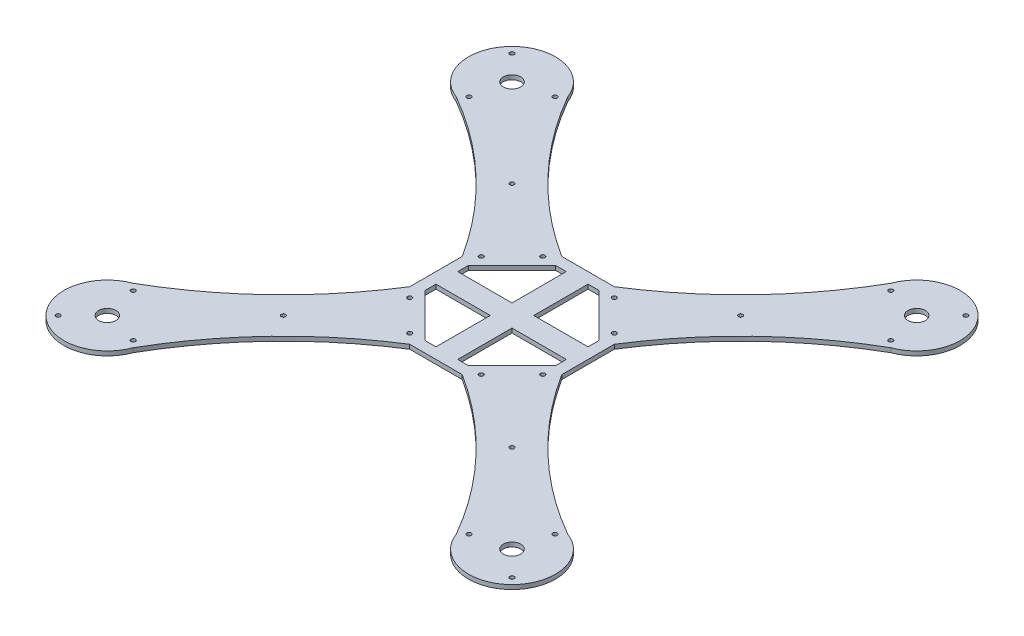
from build123d import *

# Parameters (mm, degrees)
SKETCH2_R           = 4
SKETCH2_R_2         = 1
BOSS_EXTRUDE1_DEPTH = 2
CIRPATTERN1_COUNT   = 4


with BuildPart() as part:
    # Sketch2 → Boss-Extrude1 (new body)
    with BuildSketch(Plane(origin=(0, 0, 0), x_dir=(1, 0, 0), z_dir=(0, 1, 0))):
        with BuildLine():
            Line((0, 0), (35, 0))
            Line((35, 0), (35, 12.071067812))
            ThreePointArc((35, 12.071067812), (63.703714022, 47.158503121), (99.989485852, 74.331542663))
            ThreePointArc((99.989485852, 74.331542663), (107.253909229, 107.253909229), (74.331542663, 99.989485852))
            ThreePointArc((74.331542663, 99.989485852), (47.158503121, 63.703714022), (12.071067812, 35))
            Line((12.071067812, 35), (0, 35))
            Line((0, 35), (0, 0))
        make_face()
        with Locations((93.111773605, 93.111773605)):
            Circle(SKETCH2_R, mode=Mode.SUBTRACT)
        with Locations((52.588388778, 52.588388778)):
            Circle(SKETCH2_R_2, mode=Mode.SUBTRACT)
        with Locations((16.464466094, 30.606601718)):
            Circle(SKETCH2_R_2, mode=Mode.SUBTRACT)
        with Locations((30.606601718, 16.464466094)):
            Circle(SKETCH2_R_2, mode=Mode.SUBTRACT)
        with Locations((97.060009194, 77.261019321)):
            Circle(SKETCH2_R_2, mode=Mode.SUBTRACT)
        with Locations((77.261019321, 97.060009194)):
            Circle(SKETCH2_R_2, mode=Mode.SUBTRACT)
        with Locations((104.425482104, 104.425482104)):
            Circle(SKETCH2_R_2, mode=Mode.SUBTRACT)
        Polygon((5, 30), (5, 5), (30, 5), (30, 10), (10, 30), align=None, mode=Mode.SUBTRACT)
    boss_extrude1 = extrude(amount=BOSS_EXTRUDE1_DEPTH)

    # CirPattern1: Boss-Extrude1 ×4 about axis
    cirpattern1_axis = Axis((0, 0, 0), (0, 1, 0))
    for i in range(1, CIRPATTERN1_COUNT):
        add(boss_extrude1.rotate(cirpattern1_axis, i * 360 / CIRPATTERN1_COUNT))


solid = part.part
